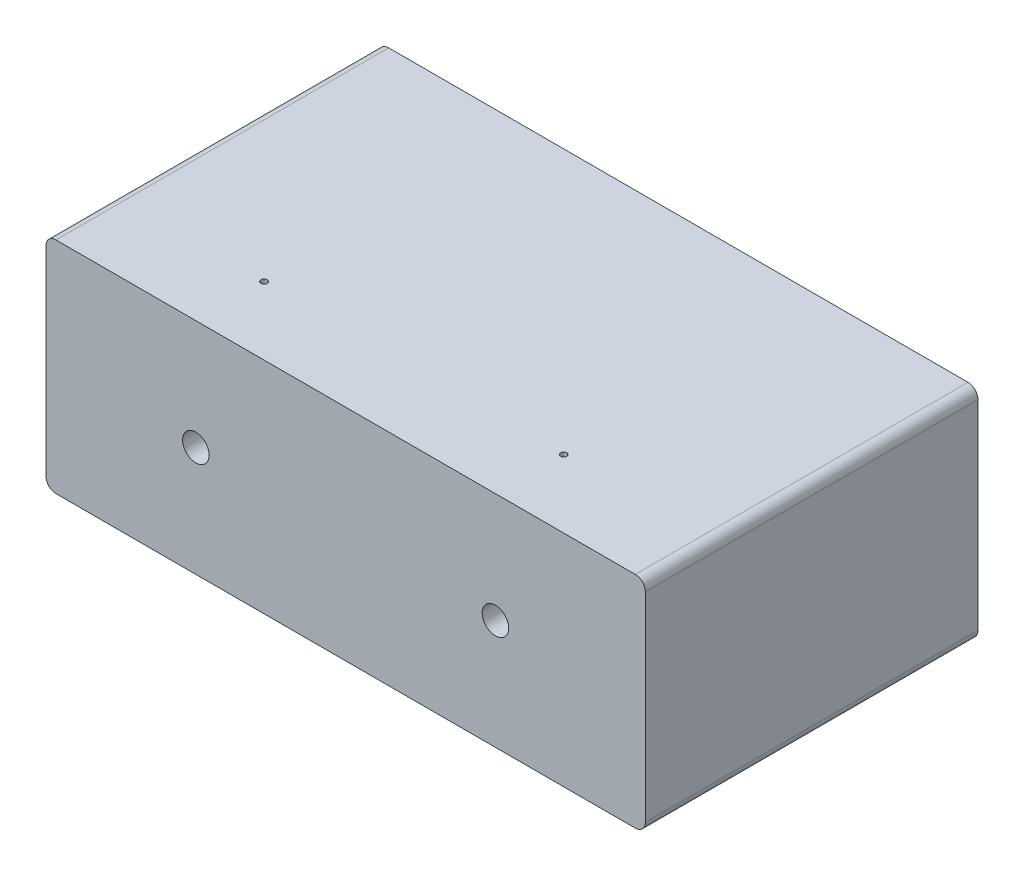
from build123d import *

# Parameters (mm, degrees)
SKETCH1_W                              = 152.4
SKETCH1_H                              = 84.6074
EXTRUDE1_DEPTH                         = 55.88
FILLET1_R                              = 2.54
TAPPED_HOLE_FOR_1_4_20_HELICOIL1_D     = 6.7564
TAPPED_HOLE_FOR_1_4_20_HELICOIL1_DEPTH = 19.685
TAPPED_HOLE_FOR_1_4_20_HELICOIL1_TIP   = 2.029827343
F_1_16_0_0625_DIAMETER_HOLE1_D         = 1.5875
F_1_16_0_0625_DIAMETER_HOLE1_DEPTH     = 27.94
F_1_16_0_0625_DIAMETER_HOLE1_TIP       = 0.476933116


with BuildPart() as part:
    # Sketch1 → Extrude1 (new body)
    with BuildSketch(Plane(origin=(0, 0, 0), x_dir=(1, 0, 0), z_dir=(0, 1, 0))):
        Rectangle(SKETCH1_W, SKETCH1_H)
    extrude(amount=EXTRUDE1_DEPTH)

    # Fillet1
    fillet1_edges = [part.edges().sort_by_distance(p)[0] for p in [
        (76.2, 55.88, 0),
        (-76.2, 55.88, 0),
        (76.2, 0, 0),
        (-76.2, 0, 0),
    ]]
    fillet(fillet1_edges, radius=FILLET1_R)

    # Tapped Hole for 1/4-20 Helicoil1
    with Locations(Plane.XY.offset(42.3037)):
        with Locations((-38.1, 27.94), (38.1, 27.94)):
            Hole(TAPPED_HOLE_FOR_1_4_20_HELICOIL1_D / 2, depth=TAPPED_HOLE_FOR_1_4_20_HELICOIL1_DEPTH)
            with Locations((0, 0, -(TAPPED_HOLE_FOR_1_4_20_HELICOIL1_DEPTH + TAPPED_HOLE_FOR_1_4_20_HELICOIL1_TIP / 2))):  # 118° drill point
                Cone(0, TAPPED_HOLE_FOR_1_4_20_HELICOIL1_D / 2, TAPPED_HOLE_FOR_1_4_20_HELICOIL1_TIP, mode=Mode.SUBTRACT)

    # 1/16 (0.0625) Diameter Hole1
    with Locations(Plane(origin=(0, 55.88, 0), x_dir=(-1, 0, 0), z_dir=(0, 1, 0))):
        with Locations((-38.160987939, 25.011375754), (38.039012061, 25.011375754)):
            Hole(F_1_16_0_0625_DIAMETER_HOLE1_D / 2, depth=F_1_16_0_0625_DIAMETER_HOLE1_DEPTH)
            with Locations((0, 0, -(F_1_16_0_0625_DIAMETER_HOLE1_DEPTH + F_1_16_0_0625_DIAMETER_HOLE1_TIP / 2))):  # 118° drill point
                Cone(0, F_1_16_0_0625_DIAMETER_HOLE1_D / 2, F_1_16_0_0625_DIAMETER_HOLE1_TIP, mode=Mode.SUBTRACT)


solid = part.part
